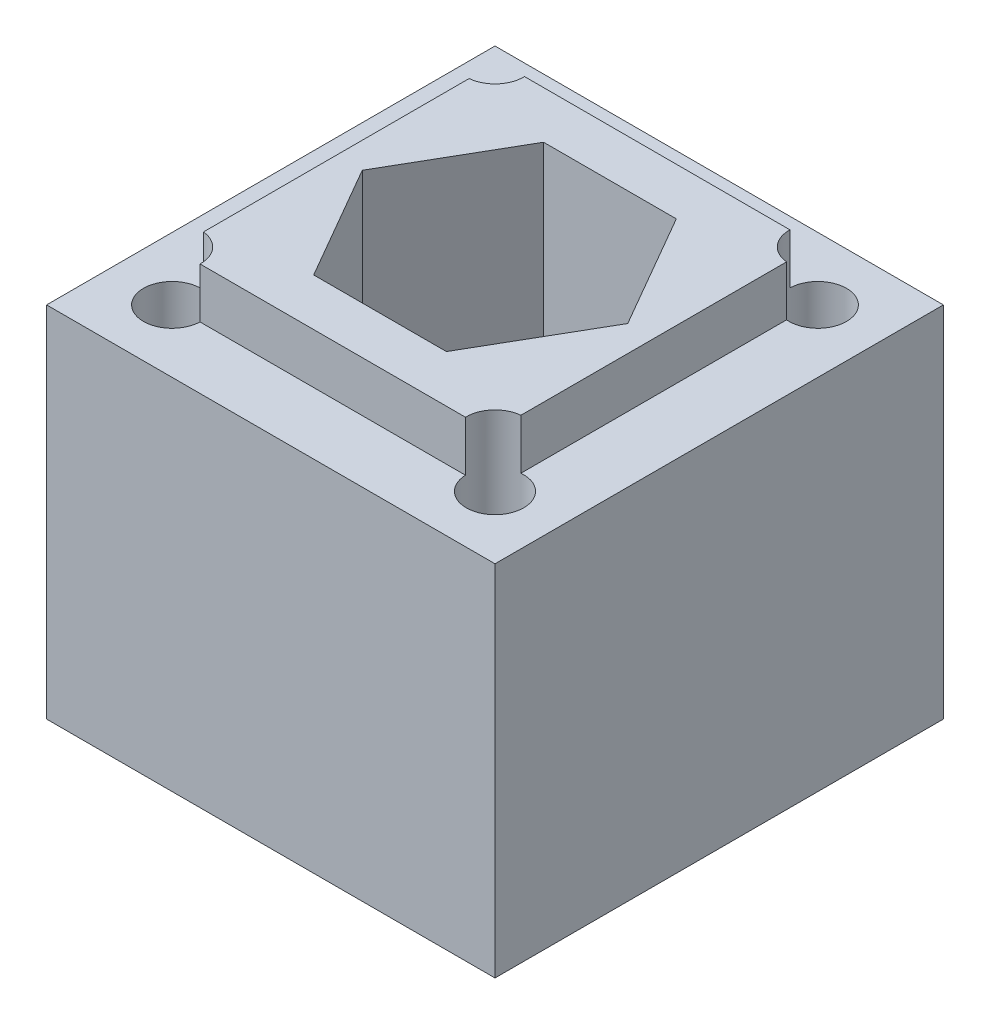
from build123d import *

# Parameters (mm, degrees)
SKETCH1_W               = 25
SKETCH1_H               = 25
BOSS_EXTRUDE1_DEPTH     = 20
SKETCH4_R               = 4.15
CUT_EXTRUDE2_DEPTH      = 21
CUT_EXTRUDE3_DEPTH      = 7
SKETCH9_W               = 17.7
SKETCH9_H               = 18.092678694
BOSS_EXTRUDE3_DEPTH     = 2.8
SKETCH6_R               = 1.6
CUT_EXTRUDE4_DEPTH      = 3.8
CUT_EXTRUDE4_DEPTH_BACK = 21


with BuildPart() as part:
    # Sketch1 → Boss-Extrude1 (new body)
    with BuildSketch(Plane(origin=(0, 0, 0), x_dir=(1, 0, 0), z_dir=(0, 1, 0))):
        Rectangle(SKETCH1_W, SKETCH1_H)
    extrude(amount=BOSS_EXTRUDE1_DEPTH)

    # Sketch4 → Cut-Extrude2 (cut, through all)
    with BuildSketch(Plane(origin=(0, 20, 0), x_dir=(1, 0, 0), z_dir=(0, 1, 0))):
        with Locations(Location((0, 0, 0), (0, 0, 270))):  # turned: the seam where the file's is
            Circle(SKETCH4_R)
    extrude(amount=-CUT_EXTRUDE2_DEPTH, mode=Mode.SUBTRACT)

    # Sketch5 → Cut-Extrude3 (cut)
    with BuildSketch(Plane(origin=(0, 20, 0), x_dir=(1, 0, 0), z_dir=(0, 1, 0))):
        Polygon((-3.7, -6.408587988), (3.7, -6.408587988), (7.4, 0), (3.7, 6.408587988), (-3.7, 6.408587988), (-7.4, 0), align=None)
    extrude(amount=-CUT_EXTRUDE3_DEPTH, mode=Mode.SUBTRACT)

    # Sketch9 → Boss-Extrude3 (add)
    with BuildSketch(Plane(origin=(0, 20, 0), x_dir=(1, 0, 0), z_dir=(0, 1, 0))):
        Rectangle(SKETCH9_W, SKETCH9_H)
        Polygon((-3.7, -6.408587988), (3.7, -6.408587988), (7.4, 0), (3.7, 6.408587988), (-3.7, 6.408587988), (-7.4, 0), align=None, mode=Mode.SUBTRACT)
    extrude(amount=BOSS_EXTRUDE3_DEPTH)

    # Sketch6 → Cut-Extrude4 (cut, two sides)
    with BuildSketch(Plane(origin=(0, 20, 0), x_dir=(1, 0, 0), z_dir=(0, 1, 0))) as cut_extrude4_sk:
        with Locations(Location((9, -9, 0), (0, 0, 270))):  # turned: the seam where the file's is
            Circle(SKETCH6_R)
        with Locations(Location((-9, -9, 0), (0, 0, 270))):  # turned: the seam where the file's is
            Circle(SKETCH6_R)
        with Locations(Location((-9, 9, 0), (0, 0, 270))):  # turned: the seam where the file's is
            Circle(SKETCH6_R)
        with Locations(Location((9, 9, 0), (0, 0, 270))):  # turned: the seam where the file's is
            Circle(SKETCH6_R)
    extrude(amount=CUT_EXTRUDE4_DEPTH, mode=Mode.SUBTRACT)
    extrude(cut_extrude4_sk.sketch, amount=-CUT_EXTRUDE4_DEPTH_BACK, mode=Mode.SUBTRACT)


solid = part.part
